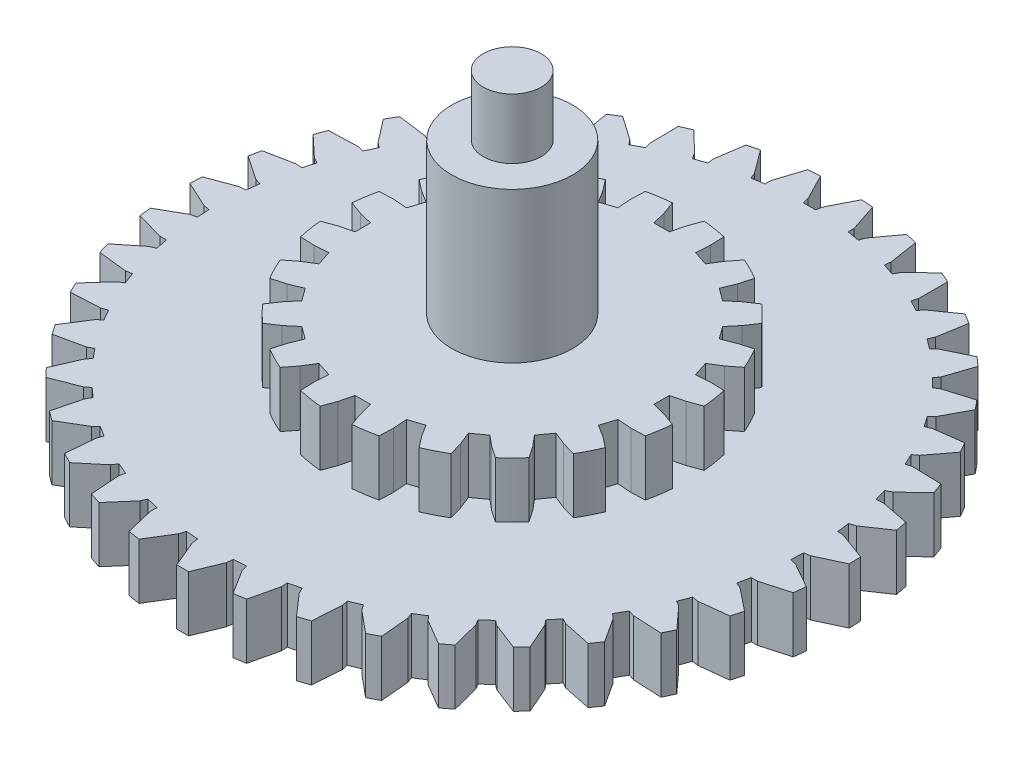
from build123d import *

# Parameters (mm, degrees)
SKETCH2_R           = 16.256
BOSS_EXTRUDE1_DEPTH = 2.7432
SKETCH3_R           = 8.71855
BOSS_EXTRUDE2_DEPTH = 2.7432
SKETCH4_R           = 2.9845
BOSS_EXTRUDE3_DEPTH = 7.4168
SKETCH5_R           = 1.42875
BOSS_EXTRUDE4_DEPTH = 2.9718
SKETCH6_R           = 1.42875
BOSS_EXTRUDE5_DEPTH = 2.9718
CUT_EXTRUDE1_DEPTH  = 6.715
CIRPATTERN15_COUNT  = 39
CUT_EXTRUDE2_DEPTH  = 2.7432
CIRPATTERN16_COUNT  = 20


with BuildPart() as part:
    # Sketch2 → Boss-Extrude1 (new body)
    with BuildSketch(Plane(origin=(0, 0, 0), x_dir=(1, 0, 0), z_dir=(0, 1, 0))):
        with Locations((-91.164639677, 64.649434019)):
            Circle(SKETCH2_R)
    extrude(amount=BOSS_EXTRUDE1_DEPTH)

    # Sketch3 → Boss-Extrude2 (add)
    with BuildSketch(Plane(origin=(0, 2.7432, 0), x_dir=(1, 0, 0), z_dir=(0, 1, 0))):
        with Locations((-91.164639677, 64.649434019)):
            Circle(SKETCH3_R)
    extrude(amount=BOSS_EXTRUDE2_DEPTH)

    # Sketch4 → Boss-Extrude3 (add)
    with BuildSketch(Plane(origin=(0, 5.4864, 0), x_dir=(1, 0, 0), z_dir=(0, 1, 0))):
        with Locations((-91.164639677, 64.649434019)):
            Circle(SKETCH4_R)
    extrude(amount=BOSS_EXTRUDE3_DEPTH)

    # Sketch5 → Boss-Extrude4 (add)
    with BuildSketch(Plane(origin=(0, 12.9032, 0), x_dir=(1, 0, 0), z_dir=(0, 1, 0))):
        with Locations((-91.164639677, 64.649434019)):
            Circle(SKETCH5_R)
    extrude(amount=BOSS_EXTRUDE4_DEPTH)

    # Sketch6 → Boss-Extrude5 (add)
    with BuildSketch(Plane.XZ):
        with Locations((-91.164639677, -64.649434019)):
            Circle(SKETCH6_R)
    extrude(amount=BOSS_EXTRUDE5_DEPTH)

    # Sketch8 → Cut-Extrude1 (cut, through all)
    with BuildSketch(Plane(origin=(0, 2.7432, 0), x_dir=(1, 0, 0), z_dir=(0, 1, 0))):
        Polygon((-91.164639677, 79.305234019), (-90.859839677, 79.305234019), (-90.801308926, 79.605278338), (-90.153807368, 80.87397574), (-90.153807368, 81.76293692), (-92.18462516, 81.540055268), (-92.18462516, 80.873402881), (-91.529216227, 79.604114939), (-91.469439677, 79.305234019), align=None)
    cut_extrude1 = extrude(amount=-CUT_EXTRUDE1_DEPTH, mode=Mode.SUBTRACT)

    # CirPattern15: Cut-Extrude1 ×39 about axis
    cirpattern15_axis = Axis((-91.164639677, 0, -64.649434019), (0, 1, 0))
    for i in range(1, CIRPATTERN15_COUNT):
        add(cut_extrude1.rotate(cirpattern15_axis, i * 360 / CIRPATTERN15_COUNT), mode=Mode.SUBTRACT)

    # Sketch10 → Cut-Extrude2 (cut)
    with BuildSketch(Plane(origin=(0, 5.4864, 0), x_dir=(1, 0, 0), z_dir=(0, 1, 0))):
        Polygon((-91.164639677, 72.017974019), (-91.545639677, 72.017974019), (-91.711549713, 72.683402828), (-91.9478857, 73.332730615), (-91.9478857, 73.520666697), (-90.307916786, 73.58340819), (-90.381393654, 73.332730615), (-90.617729641, 72.683402828), (-90.783639677, 72.017974019), align=None)
    cut_extrude2 = extrude(amount=-CUT_EXTRUDE2_DEPTH, mode=Mode.SUBTRACT)

    # CirPattern16: Cut-Extrude2 ×20 about axis
    cirpattern16_axis = Axis((-91.164639677, 0, -64.649434019), (0, 1, 0))
    for i in range(1, CIRPATTERN16_COUNT):
        add(cut_extrude2.rotate(cirpattern16_axis, i * 360 / CIRPATTERN16_COUNT), mode=Mode.SUBTRACT)


solid = part.part
